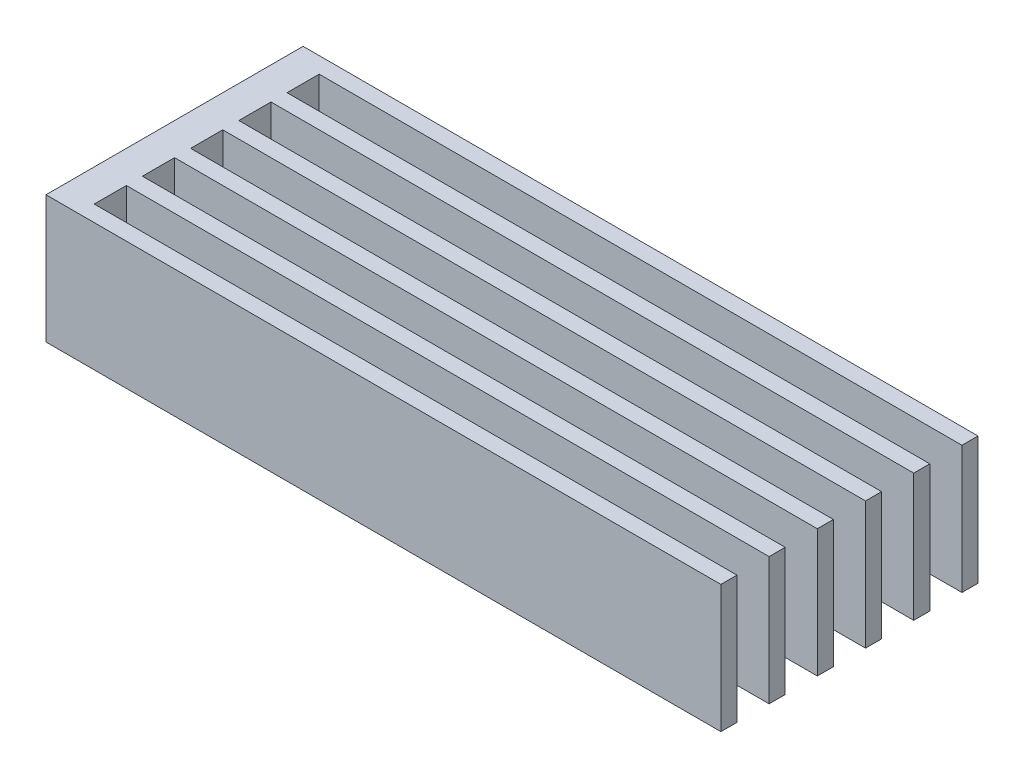
from build123d import *

# Parameters (mm, degrees)
SKETCH1_W           = 2
SKETCH1_H           = 16
BOSS_EXTRUDE1_DEPTH = 7.9375
SKETCH1_4_W         = 40
SKETCH1_4_H         = 1
BOSS_EXTRUDE2_DEPTH = 7.9375
LPATTERN1_COUNT     = 6
LPATTERN1_PITCH     = 3


with BuildPart() as part:
    # Sketch1 → Boss-Extrude1 (new body)
    with BuildSketch(Plane(origin=(0, 0, 0), x_dir=(1, 0, 0), z_dir=(0, 1, 0))):
        with Locations((-9.581037754, 12.413793103)):
            Rectangle(SKETCH1_W, SKETCH1_H)
    extrude(amount=BOSS_EXTRUDE1_DEPTH)

    # Sketch1_4 → Boss-Extrude2 (add)
    with BuildSketch(Plane(origin=(0, 0, 0), x_dir=(1, 0, 0), z_dir=(0, 1, 0))):
        with Locations((11.418962246, 19.913793103)):
            Rectangle(SKETCH1_4_W, SKETCH1_4_H)
    boss_extrude2 = extrude(amount=BOSS_EXTRUDE2_DEPTH)

    # LPattern1: Boss-Extrude2 ×6
    with Locations(*[(0, 0, i * LPATTERN1_PITCH) for i in range(1, LPATTERN1_COUNT)]):
        add(boss_extrude2)


solid = part.part
